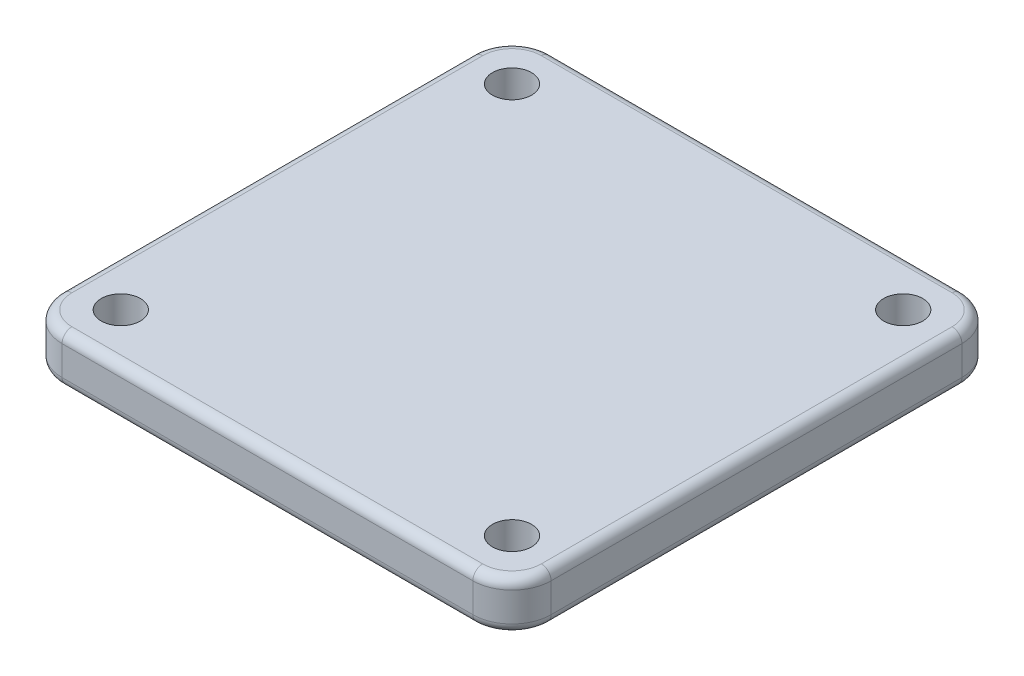
from build123d import *

# Parameters (mm, degrees)
SKETCH1_R           = 10
SKETCH1_R_2         = 5
BOSS_EXTRUDE1_DEPTH = 10
SKETCH2_R           = 2
BOSS_EXTRUDE2_DEPTH = 5
SKETCH3_R           = 1.5
CUT_EXTRUDE1_DEPTH  = 26
FILLET1_R           = 1


with BuildPart() as part:
    # Sketch1 → Boss-Extrude1 (new body)
    with BuildSketch(Plane(origin=(0, 0, 0), x_dir=(1, 0, 0), z_dir=(0, 1, 0))):
        Circle(SKETCH1_R)
        Circle(SKETCH1_R_2, mode=Mode.SUBTRACT)
    extrude(amount=BOSS_EXTRUDE1_DEPTH)

    # Sketch2 → Boss-Extrude2 (add)
    with BuildSketch(Plane(origin=(0, 10, 0), x_dir=(1, 0, 0), z_dir=(0, 1, 0))):
        with BuildLine():
            Line((-21, -25), (21, -25))
            ThreePointArc((21, -25), (23.828427125, -23.828427125), (25, -21))
            Line((25, -21), (25, 21))
            ThreePointArc((25, 21), (23.828427125, 23.828427125), (21, 25))
            Line((21, 25), (-21, 25))
            ThreePointArc((-21, 25), (-23.828427125, 23.828427125), (-25, 21))
            Line((-25, 21), (-25, -21))
            ThreePointArc((-25, -21), (-23.828427125, -23.828427125), (-21, -25))
        make_face()
        with Locations((-20, 20)):
            Circle(SKETCH2_R, mode=Mode.SUBTRACT)
        with Locations((20, 20)):
            Circle(SKETCH2_R, mode=Mode.SUBTRACT)
        with Locations((20, -20)):
            Circle(SKETCH2_R, mode=Mode.SUBTRACT)
        with Locations((-20, -20)):
            Circle(SKETCH2_R, mode=Mode.SUBTRACT)
    extrude(amount=BOSS_EXTRUDE2_DEPTH)

    # Sketch3 → Cut-Extrude1 (cut, through all)
    with BuildSketch(Plane.XY):
        with Locations((0, 5)):
            Circle(SKETCH3_R)
    extrude(amount=CUT_EXTRUDE1_DEPTH, mode=Mode.SUBTRACT)

    # Fillet1
    fillet1_edges = [part.edges().sort_by_distance(p)[0] for p in [
        (0, 15, 25),
        (23.828427125, 15, 23.828427125),
        (25, 15, 0),
        (23.828427125, 15, -23.828427125),
        (0, 15, -25),
        (-23.828427125, 15, -23.828427125),
        (-25, 15, 0),
        (-23.828427125, 10, 23.828427125),
        (0, 10, 25),
        (23.828427125, 10, 23.828427125),
        (25, 10, 0),
        (23.828427125, 10, -23.828427125),
        (0, 10, -25),
        (-23.828427125, 10, -23.828427125),
        (-25, 10, 0),
        (-23.828427125, 15, 23.828427125),
    ]]
    fillet(fillet1_edges, radius=FILLET1_R)


solid = part.part
